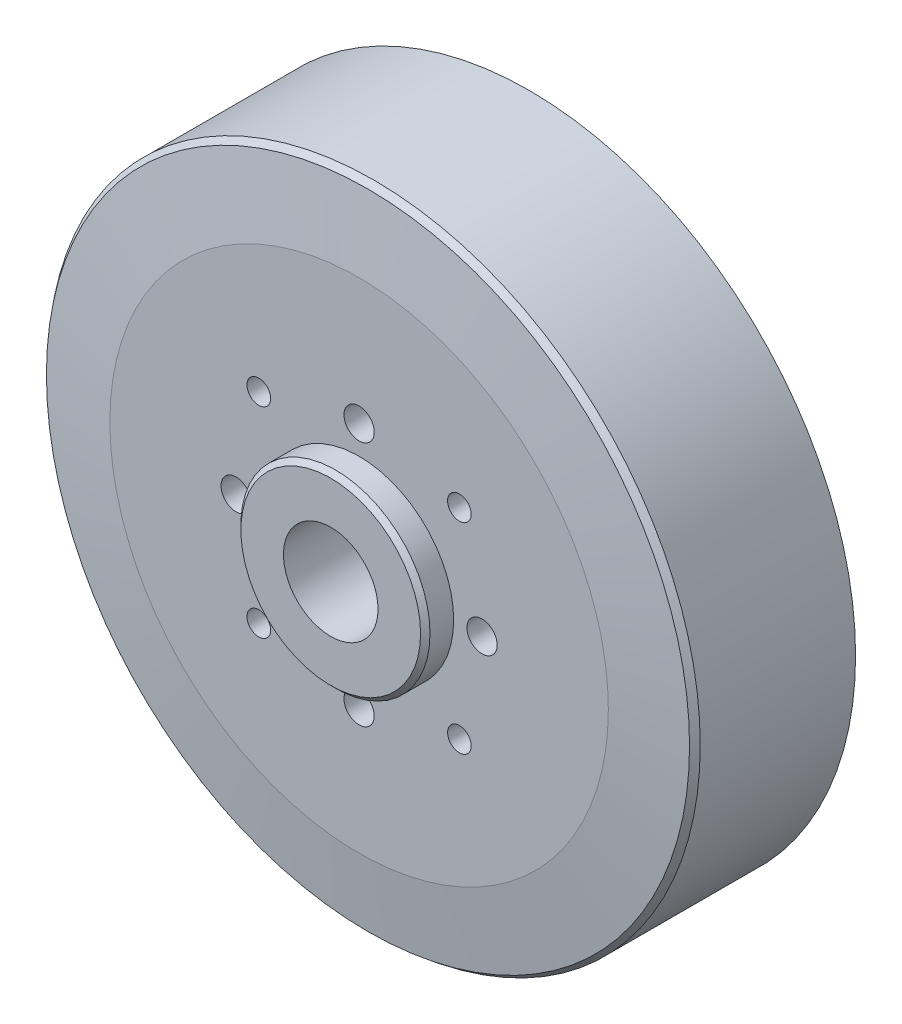
from build123d import *

# Parameters (mm, degrees)
SKETCH2_R                  = 34.5
BOSS_EXTRUDE1_DEPTH        = 18
SKETCH3_R                  = 10
BOSS_EXTRUDE2_DEPTH        = 3
CHAMFER1_SIZE              = 1
CHAMFER1_SIZE2             = 8.144346428
SKETCH4_R                  = 5
CUT_EXTRUDE1_DEPTH         = 21
SKETCH5_R                  = 30
CUT_EXTRUDE2_DEPTH         = 11
M3_TAPPED_HOLE1_D          = 2.5
F_3_2_3_2_DIAMETER_HOLE1_D = 3.2
CHAMFER2_SIZE2             = 0.5
CHAMFER2_SIZE              = 0.574265899
CHAMFER2_EDGE_2_SIZE       = 0.5
SKETCH10_R                 = 8.5
BOSS_EXTRUDE3_DEPTH        = 15
CUT_EXTRUDE3_REACH         = 27
SKETCH11_R                 = 3.5


with BuildPart() as part:
    # Sketch2 → Boss-Extrude1 (new body)
    with BuildSketch(Plane.XY):
        Circle(SKETCH2_R)
    extrude(amount=BOSS_EXTRUDE1_DEPTH)

    # Sketch3 → Boss-Extrude2 (add)
    with BuildSketch(Plane.XY.offset(18)):
        Circle(SKETCH3_R)
    extrude(amount=BOSS_EXTRUDE2_DEPTH)

    # Chamfer1
    chamfer1_edges = [part.edges().sort_by_distance(p)[0] for p in [
        (-34.5, 0, 18),
    ]]
    chamfer1_side = [part.faces().sort_by_distance(p)[0] for p in [
        (-34.5, 0, 9),
    ]]
    chamfer(chamfer1_edges, length=CHAMFER1_SIZE, length2=CHAMFER1_SIZE2, reference=chamfer1_side[0])

    # Sketch4 → Cut-Extrude1 (cut)
    with BuildSketch(Plane.XY.offset(21)):
        Circle(SKETCH4_R)
    extrude(amount=-CUT_EXTRUDE1_DEPTH, mode=Mode.SUBTRACT)

    # Sketch5 → Cut-Extrude2 (cut)
    with BuildSketch(Plane(origin=(0, 0, 0), x_dir=(-1, 0, 0), z_dir=(0, 0, -1))):
        Circle(SKETCH5_R)
    extrude(amount=-CUT_EXTRUDE2_DEPTH, mode=Mode.SUBTRACT)

    # M3 Tapped Hole1 (through all)
    with Locations(Plane.XY.offset(18)):
        with Locations((10.606601718, 10.606601718), (10.606601718, -10.606601718), (-10.606601718, -10.606601718), (-10.606601718, 10.606601718)):
            Hole(M3_TAPPED_HOLE1_D / 2)

    # Ø3.2 (3.2) Diameter Hole1 (through all)
    with Locations(Plane.XY.offset(18)):
        with Locations((13, 0), (-13, 0), (0, 13), (0, -13)):
            Hole(F_3_2_3_2_DIAMETER_HOLE1_D / 2)

    # Chamfer2
    chamfer2_edges = [part.edges().sort_by_distance(p)[0] for p in [
        (-34.5, 0, 17),
    ]]
    chamfer(chamfer2_edges, length=CHAMFER2_SIZE, length2=CHAMFER2_SIZE2)

    # Chamfer2 edge 2
    chamfer2_edge_2_edges = [part.edges().sort_by_distance(p)[0] for p in [
        (-10, 0, 21),
    ]]
    chamfer(chamfer2_edge_2_edges, length=CHAMFER2_EDGE_2_SIZE)

    # Sketch10 → Boss-Extrude3 (add)
    with BuildSketch(Plane(origin=(0, 0, 11), x_dir=(-1, 0, 0), z_dir=(0, 0, -1))):
        Circle(SKETCH10_R)
    extrude(amount=BOSS_EXTRUDE3_DEPTH)

    # Sketch11 → Cut-Extrude3 (cut, up to next)
    with BuildSketch(Plane(origin=(0, 0, -4), x_dir=(-1, 0, 0), z_dir=(0, 0, -1)), mode=Mode.PRIVATE) as cut_extrude3_sk1:
        Circle(SKETCH11_R)
    cut_extrude3_tool1 = extrude(cut_extrude3_sk1.sketch, amount=-CUT_EXTRUDE3_REACH, mode=Mode.PRIVATE) & part.part
    add(cut_extrude3_tool1.solids().sort_by_distance((0, 0, -4))[0], mode=Mode.SUBTRACT)


solid = part.part
